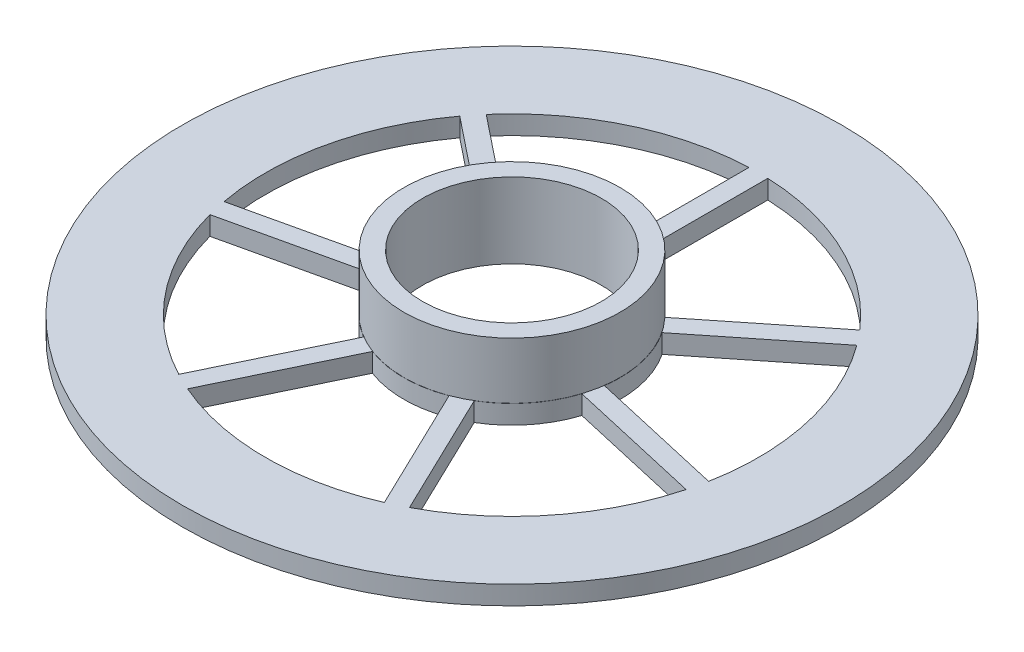
from build123d import *

# Parameters (mm, degrees)
SKETCH_1_R          = 35
SKETCH_1_R_2        = 9.5
EXTRUDE_1_DEPTH     = 18
SKETCH_2_R          = 40.856384021
SKETCH_2_R_2        = 11.482609949
CUT_EXTRUDE_1_DEPTH = 16
SKETCH_3_R          = 16.811419883
CUT_EXTRUDE_2_DEPTH = 10


with BuildPart() as part:
    # 草图1 → 凸台-拉伸1 (new body)
    with BuildSketch(Plane(origin=(0, 0, 0), x_dir=(1, 0, 0), z_dir=(0, 1, 0))):
        Circle(SKETCH_1_R)
        Circle(SKETCH_1_R_2, mode=Mode.SUBTRACT)
        with BuildLine():
            Line((19.832862473, 17.095228055), (8.333515071, 7.924804513))
            ThreePointArc((8.333515071, 7.924804513), (4.989663, 10.361141981), (1, 11.456439237))
            Line((1, 11.456439237), (1, 26.164656621))
            ThreePointArc((1, 26.164656621), (11.360707431, 23.59075206), (19.832862473, 17.095228055))
        make_face(mode=Mode.SUBTRACT)
        with BuildLine():
            Line((-1, 26.164656621), (-1, 11.456439237))
            ThreePointArc((-1, 11.456439237), (-4.989663, 10.361141981), (-8.333515071, 7.924804513))
            Line((-8.333515071, 7.924804513), (-19.832862473, 17.095228055))
            ThreePointArc((-19.832862473, 17.095228055), (-11.360707431, 23.59075206), (-1, 26.164656621))
        make_face(mode=Mode.SUBTRACT)
        with BuildLine():
            Line((21.079842076, 15.53156509), (9.580494675, 6.361141548))
            ThreePointArc((9.580494675, 6.361141548), (11.21167099, 2.55899074), (11.391723321, -1.574369647))
            Line((11.391723321, -1.574369647), (25.731174987, -4.847255916))
            ThreePointArc((25.731174987, -4.847255916), (25.527277881, 5.826434595), (21.079842076, 15.53156509))
        make_face(mode=Mode.SUBTRACT)
        with BuildLine():
            Line((25.286133119, -6.79711174), (10.946681453, -3.524225471))
            ThreePointArc((10.946681453, -3.524225471), (8.991062048, -7.170132721), (5.871731561, -9.888011351))
            Line((5.871731561, -9.888011351), (12.253387915, -23.139657316))
            ThreePointArc((12.253387915, -23.139657316), (20.471287425, -16.325306958), (25.286133119, -6.79711174))
        make_face(mode=Mode.SUBTRACT)
        with BuildLine():
            Line((10.45145018, -24.007424794), (4.069793825, -10.755778829))
            ThreePointArc((4.069793825, -10.755778829), (0, -11.5), (-4.069793825, -10.755778829))
            Line((-4.069793825, -10.755778829), (-10.45145018, -24.007424794))
            ThreePointArc((-10.45145018, -24.007424794), (0, -26.183759396), (10.45145018, -24.007424794))
        make_face(mode=Mode.SUBTRACT)
        with BuildLine():
            Line((-12.253387915, -23.139657316), (-5.871731561, -9.888011351))
            ThreePointArc((-5.871731561, -9.888011351), (-8.991062048, -7.170132721), (-10.946681453, -3.524225471))
            Line((-10.946681453, -3.524225471), (-25.286133119, -6.79711174))
            ThreePointArc((-25.286133119, -6.79711174), (-20.471287425, -16.325306958), (-12.253387915, -23.139657316))
        make_face(mode=Mode.SUBTRACT)
        with BuildLine():
            Line((-25.731174987, -4.847255916), (-11.391723321, -1.574369647))
            ThreePointArc((-11.391723321, -1.574369647), (-11.21167099, 2.55899074), (-9.580494675, 6.361141548))
            Line((-9.580494675, 6.361141548), (-21.079842076, 15.53156509))
            ThreePointArc((-21.079842076, 15.53156509), (-25.527277881, 5.826434595), (-25.731174987, -4.847255916))
        make_face(mode=Mode.SUBTRACT)
    extrude(amount=EXTRUDE_1_DEPTH)

    # 草图2 → 切除-拉伸1 (cut)
    with BuildSketch(Plane(origin=(0, 18, 0), x_dir=(1, 0, 0), z_dir=(0, 1, 0))):
        Circle(SKETCH_2_R)
        Circle(SKETCH_2_R_2, mode=Mode.SUBTRACT)
    extrude(amount=-CUT_EXTRUDE_1_DEPTH, mode=Mode.SUBTRACT)

    # 草图3 → 切除-拉伸2 (cut)
    with BuildSketch(Plane(origin=(0, 18, 0), x_dir=(1, 0, 0), z_dir=(0, 1, 0))):
        Circle(SKETCH_3_R)
    extrude(amount=-CUT_EXTRUDE_2_DEPTH, mode=Mode.SUBTRACT)


solid = part.part
